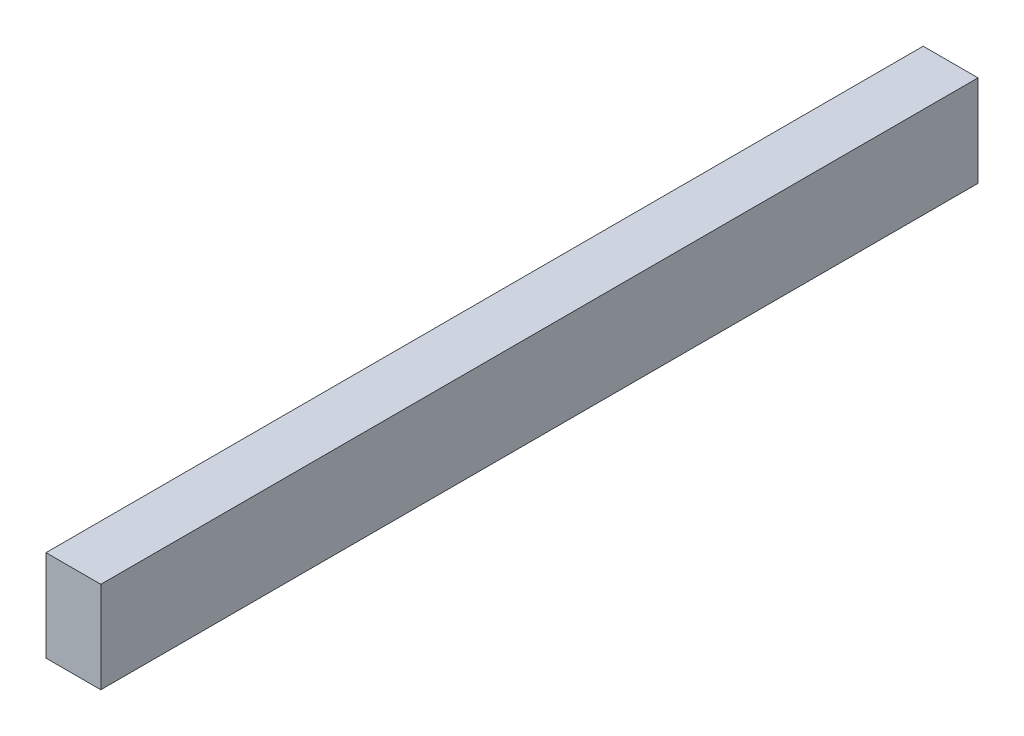
from build123d import *

# Parameters (mm, degrees)
SKETCH1_W           = 38.1
SKETCH1_H           = 63.5
BOSS_EXTRUDE1_DEPTH = 609.6


with BuildPart() as part:
    # Sketch1 → Boss-Extrude1 (new body)
    with BuildSketch(Plane.XY):
        Rectangle(SKETCH1_W, SKETCH1_H)
    extrude(amount=BOSS_EXTRUDE1_DEPTH)


solid = part.part
